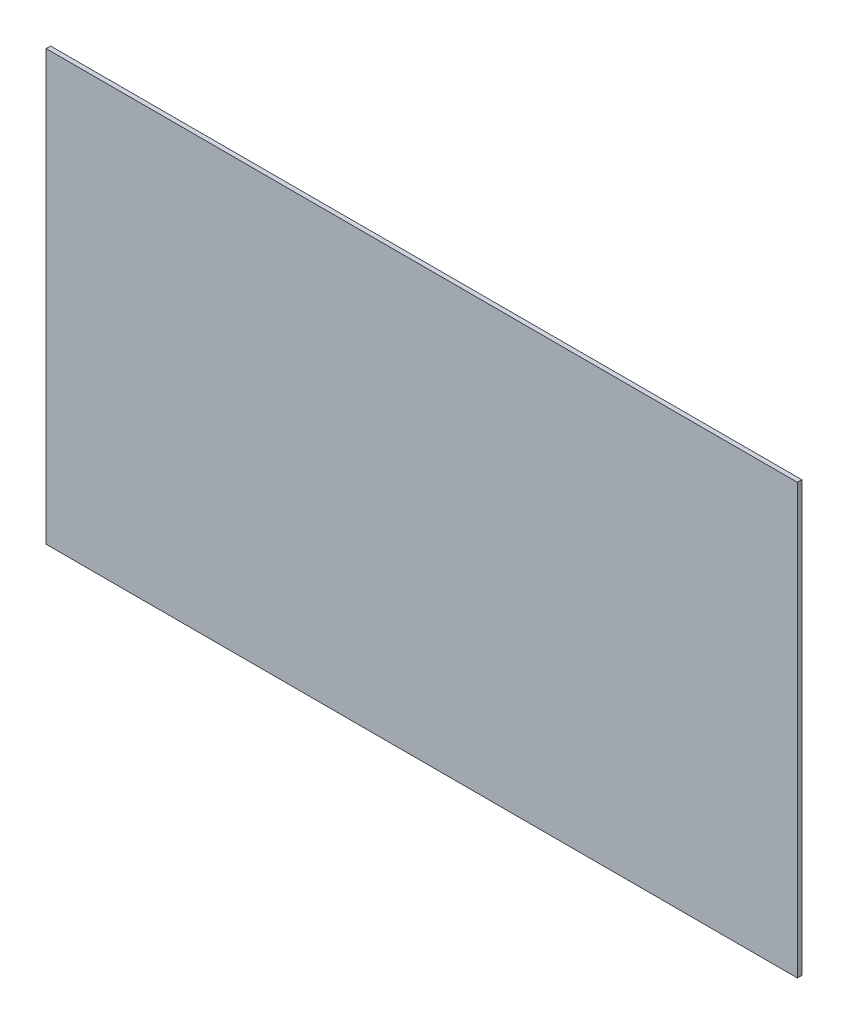
from build123d import *

# Parameters (mm, degrees)
SKETCH1_W           = 1066.8
SKETCH1_H           = 609.6
BOSS_EXTRUDE1_DEPTH = 6.35


with BuildPart() as part:
    # Sketch1 → Boss-Extrude1 (new body)
    with BuildSketch(Plane.XY):
        with Locations((-533.4, 304.8)):
            Rectangle(SKETCH1_W, SKETCH1_H)
    extrude(amount=BOSS_EXTRUDE1_DEPTH)


solid = part.part
